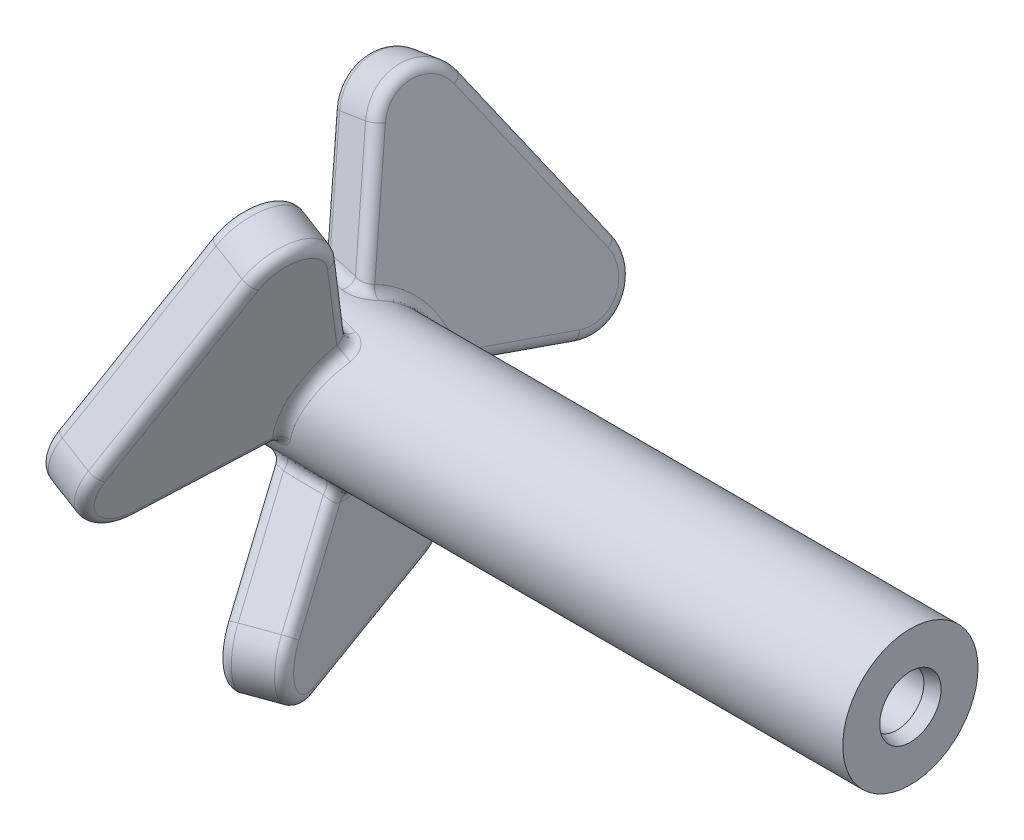
from build123d import *

# Parameters (mm, degrees)
SKETCH1_W           = 12.7
SKETCH1_H           = 1.27
BOSS_EXTRUDE1_DEPTH = 0.508
CIRPATTERN1_COUNT   = 3
FILLET1_R           = 0.889
FILLET3_R           = 0.1905
SKETCH8_R           = 0.508
CUT_EXTRUDE4_DEPTH  = 3.81
CHAMFER5_SIZE       = 0.254
CHAMFER5_SIZE2      = 0.068059095


with BuildPart() as part:
    # Sketch1 → Revolve1 (revolve)
    with BuildSketch(Plane.XY):
        with Locations((-6.35, 0.635)):
            Rectangle(SKETCH1_W, SKETCH1_H)
    revolve(axis=Axis((20.779409663, 0, 0), (-1, 0, 0)))

    # Sketch2 → Boss-Extrude1 (add, symmetric)
    with BuildSketch(Plane(origin=(-9.532224882, 0, 3.469446123), x_dir=(0.342020143, 0, 0.939692621), z_dir=(-0.939692621, 0, 0.342020143))):
        with BuildLine():
            Line((-3.692107447, 0), (-1.307948352, -2.601853089))
            ThreePointArc((-1.307948352, -2.601853089), (-1.161576004, -3.488417324), (-1.914107447, -3.979454425))
            Line((-1.914107447, -3.979454425), (-5.470107447, -3.979454425))
            ThreePointArc((-5.470107447, -3.979454425), (-6.22263889, -3.488417324), (-6.076266543, -2.601853089))
            Line((-6.076266543, -2.601853089), (-3.692107447, 0))
        make_face()
    boss_extrude1 = extrude(amount=BOSS_EXTRUDE1_DEPTH, both=True)

    # CirPattern1: Boss-Extrude1 ×3 about axis
    cirpattern1_axis = Axis((0, 0, 0), (1, 0, 0))
    for i in range(1, CIRPATTERN1_COUNT):
        add(boss_extrude1.rotate(cirpattern1_axis, i * 360 / CIRPATTERN1_COUNT))

    # Fillet1
    fillet1_edges = [part.edges().sort_by_distance(p)[0] for p in [
        (-12.7, -1.27, 0),
    ]]
    fillet(fillet1_edges, radius=FILLET1_R)

    # Fillet3
    fillet3_edges = [part.edges().sort_by_distance(p)[0] for p in [
        (-11.095094153, -0.962126911, -0.828982392),
        (-11.288878146, -1.263495241, 0.128373582),
        (-10.86188416, -1.736571642, -1.669055355),
        (-11.183128876, -3.488417324, -2.551667957),
        (-10.317636149, -3.979454425, -0.173746233),
        (-9.452143422, -3.488417324, 2.204175491),
        (-9.746463549, -1.822481881, 1.395537589),
        (-11.843536451, -1.822481881, -1.395537589),
        (-12.137856578, -3.488417324, -2.204175491),
        (-11.272363851, -3.979454425, 0.173746233),
        (-10.406871124, -3.488417324, 2.551667957),
        (-10.72811584, -1.736571642, 1.669055355),
        (-10.301121854, 0.520572837, 1.158405767),
        (-10.494905847, 1.198983267, 0.41873515),
        (-11.095094153, -0.236856356, 1.247717543),
        (-11.288878146, 0.742922404, 1.030032185),
        (-10.86188416, -0.577158517, 2.338442835),
        (-11.183128876, -0.46560061, 4.296892),
        (-10.317636149, 1.839258561, 3.533181742),
        (-9.452143422, 3.653080632, 1.918970276),
        (-9.746463549, 2.119811944, 0.880546812),
        (-11.843536451, -0.297330063, 2.276084401),
        (-12.137856578, -0.164663307, 4.123145767),
        (-11.272363851, 2.140195864, 3.359435509),
        (-10.406871124, 3.954017935, 1.745224043),
        (-10.72811584, 2.313730159, 0.669387479),
        (-10.301121854, 0.742922404, -1.030032185),
        (-10.494905847, -0.236856356, -1.247717543),
        (-11.095094153, 1.198983267, -0.41873515),
        (-11.288878146, 0.520572837, -1.158405767),
        (-10.86188416, 2.313730159, -0.669387479),
        (-11.183128876, 3.954017935, -1.745224043),
        (-10.317636149, 2.140195864, -3.359435509),
        (-9.452143422, -0.164663307, -4.123145767),
        (-9.746463549, -0.297330063, -2.276084401),
        (-11.843536451, 2.119811944, -0.880546812),
        (-12.137856578, 3.653080632, -1.918970276),
        (-11.272363851, 1.839258561, -3.533181742),
        (-10.406871124, -0.46560061, -4.296892),
        (-10.72811584, -0.577158517, -2.338442835),
        (-10.301121854, -1.263495241, -0.128373582),
        (-10.494905847, -0.962126911, 0.828982392),
    ]]
    fillet(fillet3_edges, radius=FILLET3_R)

    # Sketch8 → Cut-Extrude4 (cut)
    with BuildSketch(Plane(origin=(0, 0, 0), x_dir=(0, 0, -1), z_dir=(1, 0, 0))):
        Circle(SKETCH8_R)
    extrude(amount=-CUT_EXTRUDE4_DEPTH, mode=Mode.SUBTRACT)

    # Chamfer5
    chamfer5_edges = [part.edges().sort_by_distance(p)[0] for p in [
        (0, 0, 0.508),
    ]]
    chamfer5_side = [part.faces().sort_by_distance(p)[0] for p in [
        (-1.905, 0, 0.508),
    ]]
    chamfer(chamfer5_edges, length=CHAMFER5_SIZE, length2=CHAMFER5_SIZE2, reference=chamfer5_side[0])


solid = part.part
